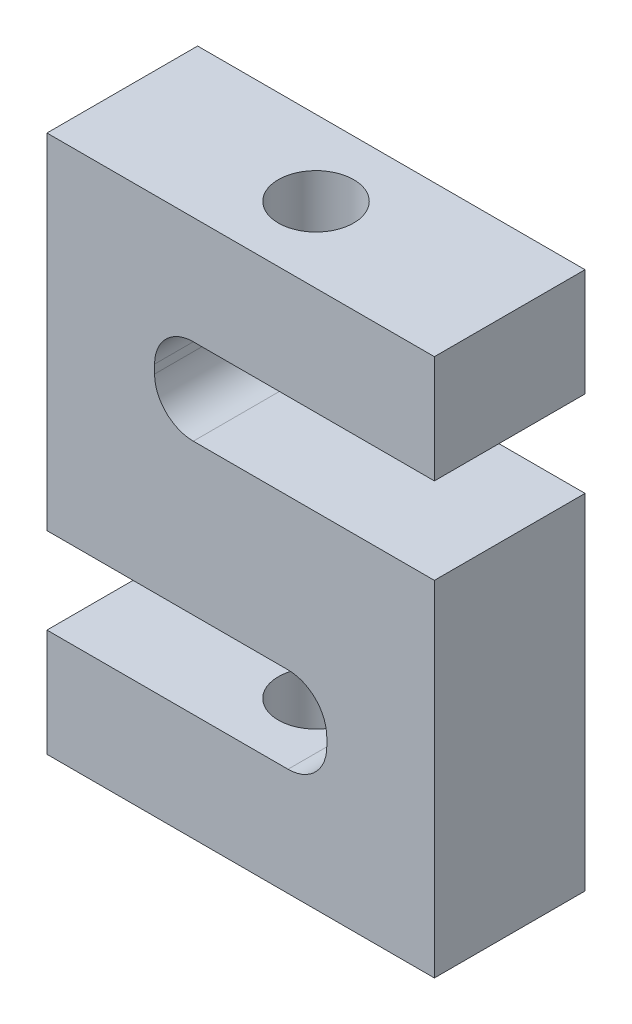
from build123d import *

# Parameters (mm, degrees)
BOSS_EXTRUDE1_DEPTH      = 44.45
FILLET1_R                = 11.43
F_1_8_TAPPED_HOLE1_D     = 22.225
F_1_8_TAPPED_HOLE1_DEPTH = 31.75
F_1_8_TAPPED_HOLE2_D     = 22.225
F_1_8_TAPPED_HOLE2_DEPTH = 31.75


with BuildPart() as part:
    # Sketch1 → Boss-Extrude1 (new body)
    with BuildSketch(Plane.XY):
        Polygon((82.55, 0), (0, 0), (0, 25.4), (82.55, 25.4), (82.55, 57.15), (-31.75, 57.15), (-31.75, -44.45), (50.8, -44.45), (50.8, -69.85), (-31.75, -69.85), (-31.75, -101.6), (82.55, -101.6), align=None)
    extrude(amount=BOSS_EXTRUDE1_DEPTH)

    # Fillet1
    fillet1_edges = [part.edges().sort_by_distance(p)[0] for p in [
        (50.8, -69.85, 22.225),
        (50.8, -44.45, 22.225),
        (0, 25.4, 22.225),
        (0, 0, 22.225),
    ]]
    fillet(fillet1_edges, radius=FILLET1_R)

    # 1-8 Tapped Hole1
    with Locations(Plane.XZ.offset(101.6)):
        with Locations((25.4, 22.225)):
            Hole(F_1_8_TAPPED_HOLE1_D / 2, depth=F_1_8_TAPPED_HOLE1_DEPTH)

    # 1-8 Tapped Hole2
    with Locations(Plane(origin=(0, 57.15, 0), x_dir=(-1, 0, 0), z_dir=(0, 1, 0))):
        with Locations((-25.4, 22.225)):
            Hole(F_1_8_TAPPED_HOLE2_D / 2, depth=F_1_8_TAPPED_HOLE2_DEPTH)


solid = part.part
